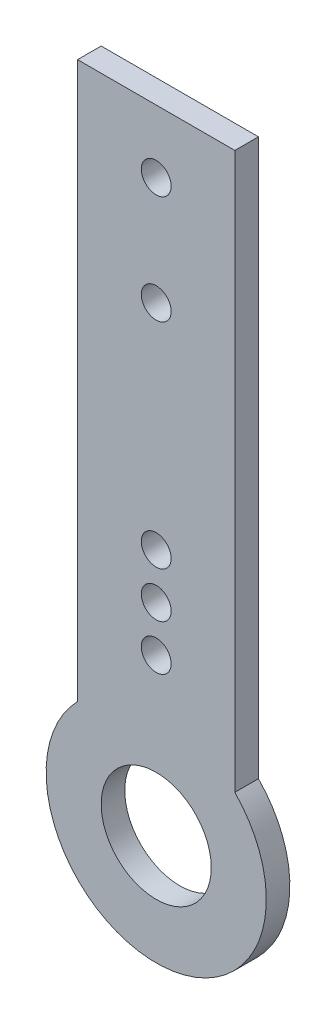
from build123d import *

# Parameters (mm, degrees)
SKETCH_1_R      = 3.5
SKETCH_1_R_2    = 0.95
EXTRUDE_2_DEPTH = 1.5


with BuildPart() as part:
    # 草图1 → 凸台-拉伸2 (new body)
    with BuildSketch(Plane.XY):
        with BuildLine():
            ThreePointArc((-5, 4.898979486), (0, -7), (5, 4.898979486))
            Line((5, 4.898979486), (5, 40.25))
            Line((5, 40.25), (-5, 40.25))
            Line((-5, 40.25), (-5, 4.898979486))
        make_face()
        Circle(SKETCH_1_R, mode=Mode.SUBTRACT)
        with Locations((0, 36.25)):
            Circle(SKETCH_1_R_2, mode=Mode.SUBTRACT)
        with Locations((0, 9.95)):
            Circle(SKETCH_1_R_2, mode=Mode.SUBTRACT)
        with Locations((0, 12.85)):
            Circle(SKETCH_1_R_2, mode=Mode.SUBTRACT)
        with Locations((0, 15.75)):
            Circle(SKETCH_1_R_2, mode=Mode.SUBTRACT)
        with Locations((0, 29.35)):
            Circle(SKETCH_1_R_2, mode=Mode.SUBTRACT)
    extrude(amount=EXTRUDE_2_DEPTH)


solid = part.part
